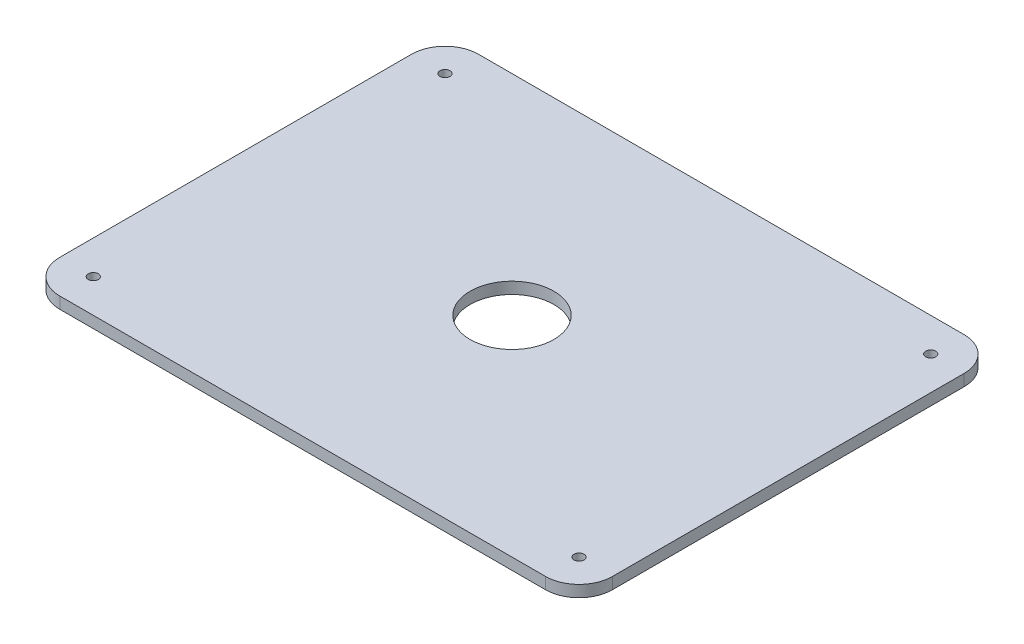
from build123d import *

# Parameters (mm, degrees)
SKETCH1_W           = 330
SKETCH1_H           = 250
BOSS_EXTRUDE1_DEPTH = 6.9
SKETCH2_R           = 3
CUT_EXTRUDE1_DEPTH  = 7.9
SKETCH3_R           = 25
CUT_EXTRUDE2_DEPTH  = 7.9
FILLET1_R           = 20


with BuildPart() as part:
    # Sketch1 → Boss-Extrude1 (new body)
    with BuildSketch(Plane(origin=(0, 0, 0), x_dir=(1, 0, 0), z_dir=(0, 1, 0))):
        Rectangle(SKETCH1_W, SKETCH1_H)
    extrude(amount=BOSS_EXTRUDE1_DEPTH)

    # Sketch2 → Cut-Extrude1 (cut, through all)
    with BuildSketch(Plane(origin=(0, 6.9, 0), x_dir=(1, 0, 0), z_dir=(0, 1, 0))):
        with Locations((-145, 105)):
            Circle(SKETCH2_R)
        with Locations((145, 105)):
            Circle(SKETCH2_R)
        with Locations((145, -105)):
            Circle(SKETCH2_R)
        with Locations((-145, -105)):
            Circle(SKETCH2_R)
    extrude(amount=-CUT_EXTRUDE1_DEPTH, mode=Mode.SUBTRACT)

    # Sketch3 → Cut-Extrude2 (cut, through all)
    with BuildSketch(Plane(origin=(0, 6.9, 0), x_dir=(1, 0, 0), z_dir=(0, 1, 0))):
        Circle(SKETCH3_R)
    extrude(amount=-CUT_EXTRUDE2_DEPTH, mode=Mode.SUBTRACT)

    # Fillet1
    fillet1_edges = [part.edges().sort_by_distance(p)[0] for p in [
        (-165, 3.45, -125),
        (165, 3.45, -125),
        (165, 3.45, 125),
        (-165, 3.45, 125),
    ]]
    fillet(fillet1_edges, radius=FILLET1_R)


solid = part.part
